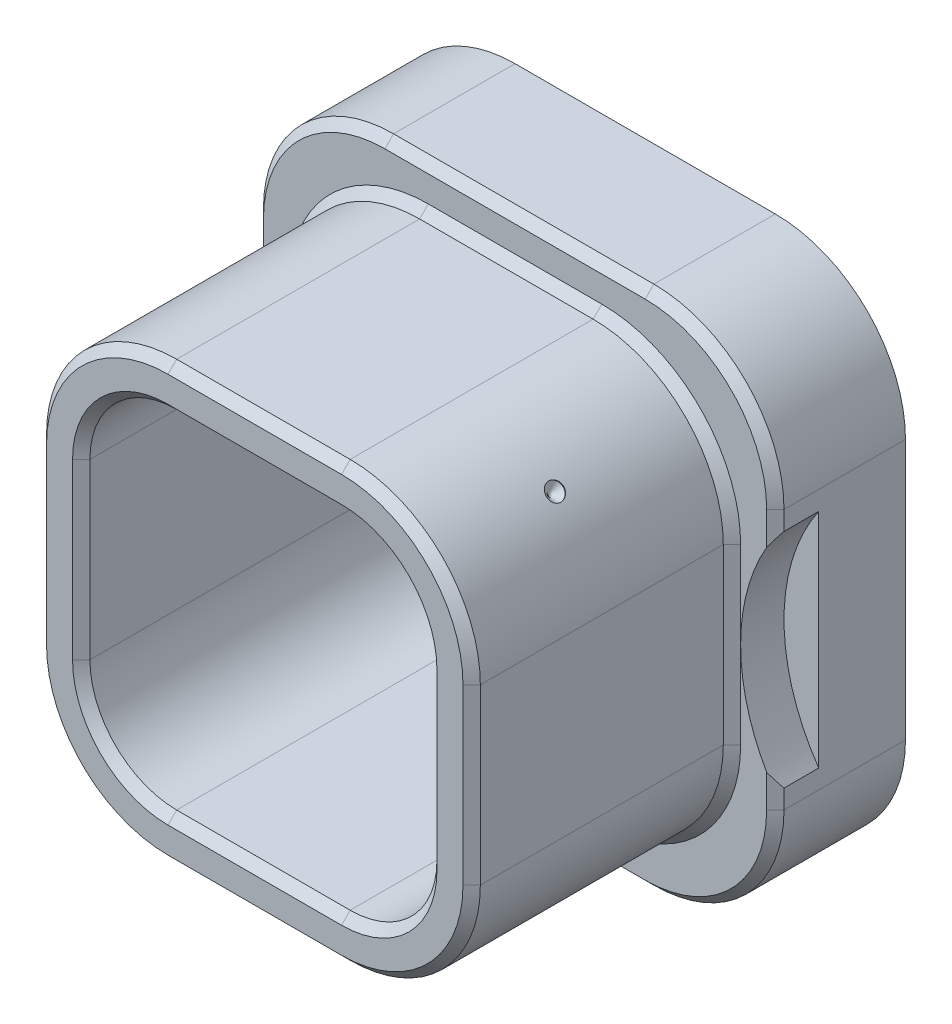
from build123d import *

# Parameters (mm, degrees)
SKIZZE1_W                            = 6
SKIZZE1_H                            = 6
AUFSATZ_LINEAR_AUSTRAGEN1_DEPTH      = 1.5
SKIZZE2_W                            = 5
SKIZZE2_H                            = 5
AUFSATZ_LINEAR_AUSTRAGEN2_DEPTH      = 3
SKIZZE3_W                            = 4
SKIZZE3_H                            = 4
SCHNITT_LINEAR_AUSTRAGEN1_DEPTH      = 3.5
VERRUNDUNG1_R                        = 1
VERRUNDUNG2_R                        = 1.5
VERRUNDUNG3_R                        = 1.5
FASE1_SIZE                           = 0.1
F_0_2_0_2_DURCHMESSER_BOHRUNG5_D     = 0.2
F_0_2_0_2_DURCHMESSER_BOHRUNG5_DEPTH = 0.01
F_0_2_0_2_DURCHMESSER_BOHRUNG5_TIP   = 0.1
SKIZZE7_R                            = 2.25
SCHNITT_LINEAR_AUSTRAGEN2_DEPTH      = 0.5


with BuildPart() as part:
    # Skizze1 → Aufsatz-Linear austragen1 (new body)
    with BuildSketch(Plane.XY):
        Rectangle(SKIZZE1_W, SKIZZE1_H)
    extrude(amount=-AUFSATZ_LINEAR_AUSTRAGEN1_DEPTH)

    # Skizze2 → Aufsatz-Linear austragen2 (add)
    with BuildSketch(Plane(origin=(0, 0, 0), x_dir=(-1, 0, 0), z_dir=(0, 0, -1))):
        Rectangle(SKIZZE2_W, SKIZZE2_H)
    extrude(amount=-AUFSATZ_LINEAR_AUSTRAGEN2_DEPTH)

    # Skizze3 → Schnitt-Linear austragen1 (cut)
    with BuildSketch(Plane.XY.offset(3)):
        Rectangle(SKIZZE3_W, SKIZZE3_H)
    extrude(amount=-SCHNITT_LINEAR_AUSTRAGEN1_DEPTH, mode=Mode.SUBTRACT)

    # Verrundung1
    verrundung1_edges = [part.edges().sort_by_distance(p)[0] for p in [
        (2, 2, 1.25),
        (2, -2, 1.25),
        (-2, -2, 1.25),
        (-2, 2, 1.25),
    ]]
    fillet(verrundung1_edges, radius=VERRUNDUNG1_R)

    # Verrundung2
    verrundung2_edges = [part.edges().sort_by_distance(p)[0] for p in [
        (-2.5, 2.5, 1.5),
        (-2.5, -2.5, 1.5),
        (2.5, -2.5, 1.5),
        (2.5, 2.5, 1.5),
    ]]
    fillet(verrundung2_edges, radius=VERRUNDUNG2_R)

    # Verrundung3
    verrundung3_edges = [part.edges().sort_by_distance(p)[0] for p in [
        (3, -3, -0.75),
        (-3, -3, -0.75),
        (-3, 3, -0.75),
        (3, 3, -0.75),
    ]]
    fillet(verrundung3_edges, radius=VERRUNDUNG3_R)

    # Fase1
    fase1_edges = [part.edges().sort_by_distance(p)[0] for p in [
        (0, -2, 3),
        (-2, 0, 3),
        (2, 0, 3),
        (0, 2, 3),
        (-1.707106781, -1.707106781, 3),
        (1.707106781, -1.707106781, 3),
        (1.707106781, 1.707106781, 3),
        (-1.707106781, 1.707106781, 3),
        (0, -2.5, 0),
        (0, -2.5, 3),
        (-2.5, 0, 0),
        (-2.5, 0, 3),
        (2.5, 0, 3),
        (0, 2.5, 3),
        (-2.060660172, 2.060660172, 3),
        (2.060660172, 2.060660172, 3),
        (2.060660172, -2.060660172, 3),
        (-2.060660172, -2.060660172, 3),
        (2.5, 0, 0),
        (0, 2.5, 0),
        (-2.060660172, -2.060660172, 0),
        (2.060660172, -2.060660172, 0),
        (2.060660172, 2.060660172, 0),
        (-2.060660172, 2.060660172, 0),
        (-3, 0, 0),
        (3, 0, 0),
        (0, 3, 0),
        (0, -3, 0),
        (-2.560660172, 2.560660172, 0),
        (2.560660172, 2.560660172, 0),
        (2.560660172, -2.560660172, 0),
        (-2.560660172, -2.560660172, 0),
    ]]
    chamfer(fase1_edges, length=FASE1_SIZE)

    # Ø0.2 (0.2) Durchmesser Bohrung5
    with Locations(Plane(origin=(2.060660172, 2.060660172, 0), x_dir=(0.707106781, -0.707106781, 0), z_dir=(0.707106781, 0.707106781, 0))):
        with Locations((0, -1.6)):
            Hole(F_0_2_0_2_DURCHMESSER_BOHRUNG5_D / 2, depth=F_0_2_0_2_DURCHMESSER_BOHRUNG5_DEPTH)
            with Locations((0, 0, -(F_0_2_0_2_DURCHMESSER_BOHRUNG5_DEPTH + F_0_2_0_2_DURCHMESSER_BOHRUNG5_TIP / 2))):  # 90° drill point
                Cone(0, F_0_2_0_2_DURCHMESSER_BOHRUNG5_D / 2, F_0_2_0_2_DURCHMESSER_BOHRUNG5_TIP, mode=Mode.SUBTRACT)

    # Skizze7 → Schnitt-Linear austragen2 (cut)
    with BuildSketch(Plane.XY):
        with Locations((-4.85, 0)):
            Circle(SKIZZE7_R)
        with Locations((4.85, 0)):
            Circle(SKIZZE7_R)
    extrude(amount=-SCHNITT_LINEAR_AUSTRAGEN2_DEPTH, mode=Mode.SUBTRACT)


solid = part.part
